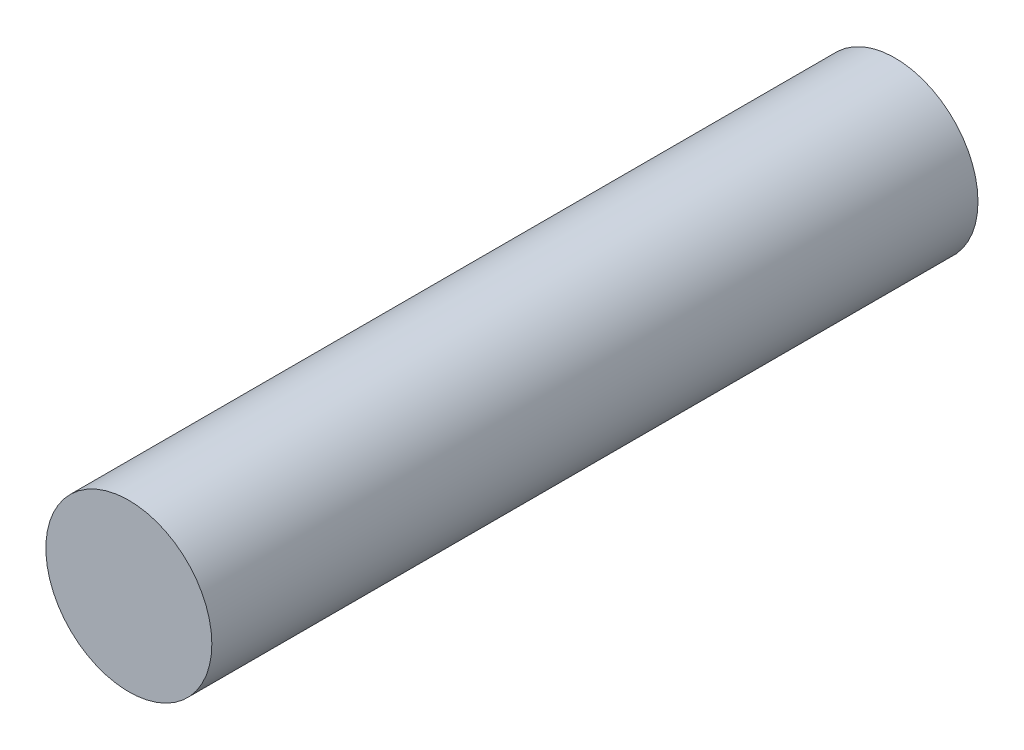
from build123d import *

# Parameters (mm, degrees)
SKETCH1_R           = 3.25
BOSS_EXTRUDE1_DEPTH = 30


with BuildPart() as part:
    # Sketch1 → Boss-Extrude1 (new body)
    with BuildSketch(Plane.XY):
        Circle(SKETCH1_R)
    extrude(amount=-BOSS_EXTRUDE1_DEPTH)


solid = part.part
